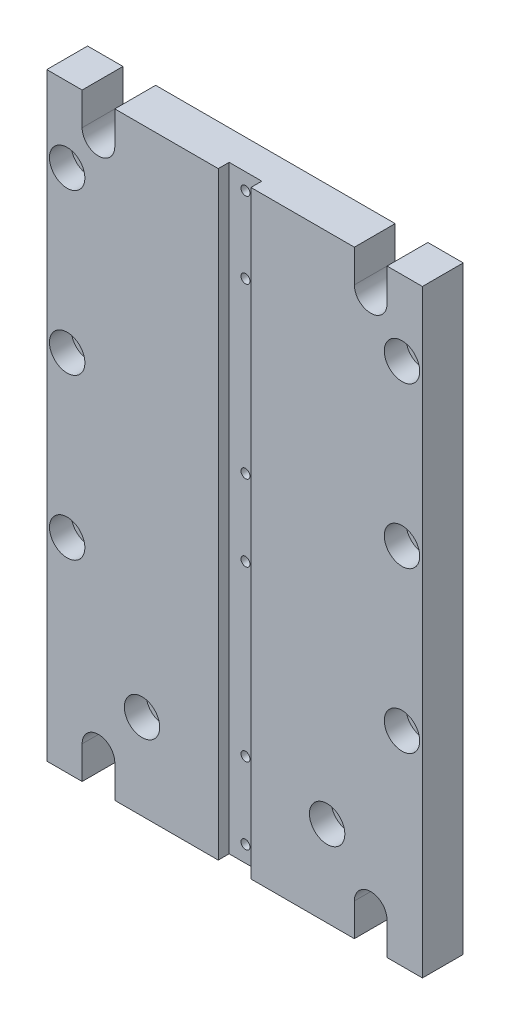
from build123d import *

# Parameters (mm, degrees)
CROQUIS1_W                = 138
CROQUIS1_H                = 220
SALIENTE_EXTRUIR1_DEPTH   = 15
CORTAR_EXTRUIR1_DEPTH     = 76.5
CROQUIS3_R                = 4.25
CORTAR_EXTRUIR2_DEPTH     = 76.5
CROQUIS4_R                = 6.5
CORTAR_EXTRUIR3_DEPTH     = 8
CROQUIS5_W                = 12
CROQUIS5_H                = 220
CORTAR_EXTRUIR4_DEPTH     = 4
TALADRO_ROSCADO_M41_D     = 3.3
TALADRO_ROSCADO_M41_DEPTH = 8
TALADRO_ROSCADO_M41_TIP   = 0.991420021
CORTAR_EXTRUIR5_DEPTH     = 8
CHAFL_N1_SIZE             = 2


with BuildPart() as part:
    # Croquis1 → Saliente-Extruir1 (new body)
    with BuildSketch(Plane.XY):
        Rectangle(CROQUIS1_W, CROQUIS1_H)
    extrude(amount=SALIENTE_EXTRUIR1_DEPTH)

    # Croquis2 → Cortar-Extruir1 (cut)
    with BuildSketch(Plane.XY.offset(15)):
        with BuildLine():
            Line((-56, 122.891872251), (-56, 98))
            ThreePointArc((-56, 98), (-50, 92), (-44, 98))
            Line((-44, 98), (-44, 122.891872251))
            Line((-44, 122.891872251), (-56, 122.891872251))
        make_face()
        with BuildLine():
            Line((44, 116.909766475), (44, 98))
            ThreePointArc((44, 98), (50, 92), (56, 98))
            Line((56, 98), (56, 116.909766475))
            Line((56, 116.909766475), (44, 116.909766475))
        make_face()
        with BuildLine():
            Line((44, -98), (44, -115.830663504))
            Line((44, -115.830663504), (56, -115.830663504))
            Line((56, -115.830663504), (56, -98))
            ThreePointArc((56, -98), (50, -92), (44, -98))
        make_face()
        with BuildLine():
            Line((-56, -98), (-56, -115.886145335))
            Line((-56, -115.886145335), (-44, -115.886145335))
            Line((-44, -115.886145335), (-44, -98))
            ThreePointArc((-44, -98), (-50, -92), (-56, -98))
        make_face()
    extrude(amount=-CORTAR_EXTRUIR1_DEPTH, mode=Mode.SUBTRACT)

    # Croquis3 → Cortar-Extruir2 (cut)
    with BuildSketch(Plane.XY.offset(15)):
        with Locations((-61.5, 82.5)):
            Circle(CROQUIS3_R)
        with Locations((-61.5, 23.7)):
            Circle(CROQUIS3_R)
        with Locations((-61.5, -35.1)):
            Circle(CROQUIS3_R)
        with Locations((-34, -78.5)):
            Circle(CROQUIS3_R)
        with Locations((34, -78.5)):
            Circle(CROQUIS3_R)
        with Locations((61.5, -35.1)):
            Circle(CROQUIS3_R)
        with Locations((61.5, 23.7)):
            Circle(CROQUIS3_R)
        with Locations((61.5, 82.5)):
            Circle(CROQUIS3_R)
    extrude(amount=-CORTAR_EXTRUIR2_DEPTH, mode=Mode.SUBTRACT)

    # Croquis4 → Cortar-Extruir3 (cut)
    with BuildSketch(Plane.XY.offset(15)):
        with Locations((-61.5, 82.5)):
            Circle(CROQUIS4_R)
        with Locations((-61.5, 23.7)):
            Circle(CROQUIS4_R)
        with Locations((-61.5, -35.1)):
            Circle(CROQUIS4_R)
        with Locations((-34, -78.5)):
            Circle(CROQUIS4_R)
        with Locations((61.5, -35.1)):
            Circle(CROQUIS4_R)
        with Locations((61.5, 23.7)):
            Circle(CROQUIS4_R)
        with Locations((61.5, 82.5)):
            Circle(CROQUIS4_R)
        with Locations((34, -78.5)):
            Circle(CROQUIS4_R)
    extrude(amount=-CORTAR_EXTRUIR3_DEPTH, mode=Mode.SUBTRACT)

    # Croquis5 → Cortar-Extruir4 (cut)
    with BuildSketch(Plane.XY.offset(15)):
        Rectangle(CROQUIS5_W, CROQUIS5_H)
    extrude(amount=-CORTAR_EXTRUIR4_DEPTH, mode=Mode.SUBTRACT)

    # Taladro roscado M41
    with Locations(Plane.XY.offset(11)):
        with Locations((0, 104), (0, 76), (0, 14), (0, -14), (0, -76), (0, -104)):
            Hole(TALADRO_ROSCADO_M41_D / 2, depth=TALADRO_ROSCADO_M41_DEPTH)
            with Locations((0, 0, -(TALADRO_ROSCADO_M41_DEPTH + TALADRO_ROSCADO_M41_TIP / 2))):  # 118° drill point
                Cone(0, TALADRO_ROSCADO_M41_D / 2, TALADRO_ROSCADO_M41_TIP, mode=Mode.SUBTRACT)

    # Croquis8 → Cortar-Extruir5 (cut)
    with BuildSketch(Plane(origin=(0, 0, 0), x_dir=(-1, 0, 0), z_dir=(0, 0, -1))):
        with BuildLine():
            Line((30, -55.5), (-30, -55.5))
            ThreePointArc((-30, -55.5), (-34.242640687, -53.742640687), (-36, -49.5))
            Line((-36, -49.5), (-36, 66.5))
            ThreePointArc((-36, 66.5), (-34.242640687, 70.742640687), (-30, 72.5))
            Line((-30, 72.5), (30, 72.5))
            ThreePointArc((30, 72.5), (34.242640687, 70.742640687), (36, 66.5))
            Line((36, 66.5), (36, -49.5))
            ThreePointArc((36, -49.5), (34.242640687, -53.742640687), (30, -55.5))
        make_face()
    extrude(amount=-CORTAR_EXTRUIR5_DEPTH, mode=Mode.SUBTRACT)

    # Chaflán1
    chafl_n1_edges = [part.edges().sort_by_distance(p)[0] for p in [
        (34.242640687, 70.742640687, 0),
        (36, 8.5, 0),
        (34.242640687, -53.742640687, 0),
        (0, -55.5, 0),
        (-34.242640687, -53.742640687, 0),
        (-36, 8.5, 0),
        (-34.242640687, 70.742640687, 0),
        (0, 72.5, 0),
    ]]
    chamfer(chafl_n1_edges, length=CHAFL_N1_SIZE)


solid = part.part
